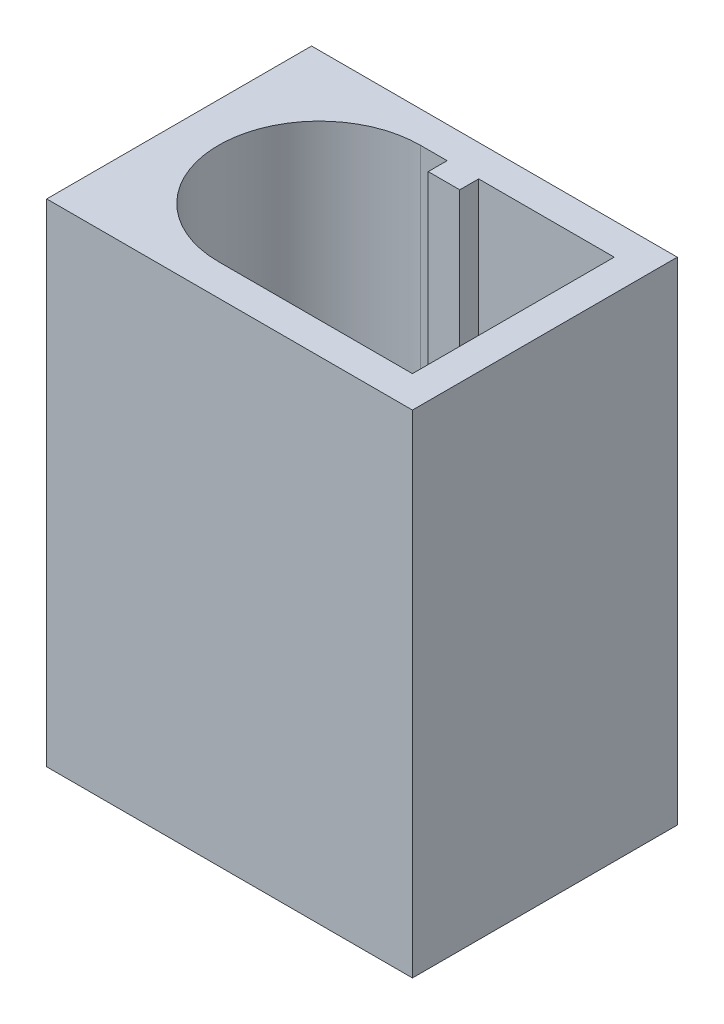
from build123d import *

# Parameters (mm, degrees)
SKETCH1_W           = 5.8
SKETCH1_H           = 4.2
BOSS_EXTRUDE1_DEPTH = 7.8
CUT_EXTRUDE1_DEPTH  = 7


with BuildPart() as part:
    # Sketch1 → Boss-Extrude1 (new body)
    with BuildSketch(Plane(origin=(0, 0, 0), x_dir=(1, 0, 0), z_dir=(0, 1, 0))):
        with Locations((2.9, 2.1)):
            Rectangle(SKETCH1_W, SKETCH1_H)
    extrude(amount=BOSS_EXTRUDE1_DEPTH)

    # Sketch2 → Cut-Extrude1 (cut)
    with BuildSketch(Plane(origin=(0, 7.8, 0), x_dir=(1, 0, 0), z_dir=(0, 1, 0))):
        with BuildLine():
            Line((2.225, 0.5), (5.3, 0.5))
            Line((5.3, 0.5), (5.3, 3.7))
            Line((5.3, 3.7), (3.15, 3.7))
            Line((3.15, 3.7), (3.15, 3.4))
            Line((3.15, 3.4), (2.65, 3.4))
            Line((2.65, 3.4), (2.65, 3.7))
            Line((2.65, 3.7), (2.225, 3.7))
            ThreePointArc((2.225, 3.7), (0.625, 2.1), (2.225, 0.5))
        make_face()
    extrude(amount=-CUT_EXTRUDE1_DEPTH, mode=Mode.SUBTRACT)


solid = part.part
